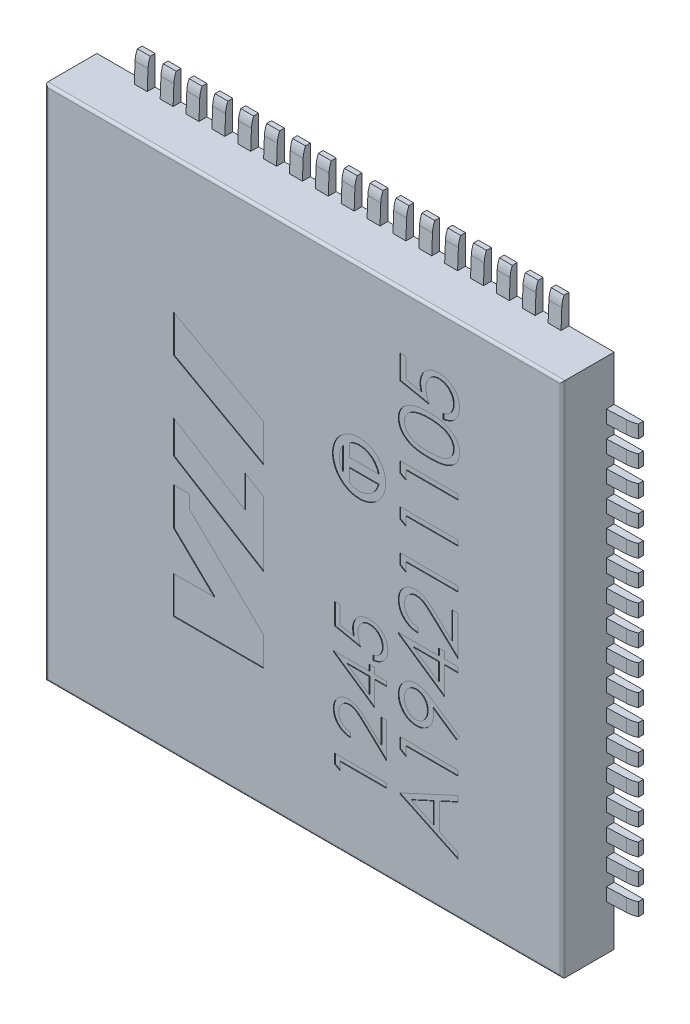
from build123d import *

# Parameters (mm, degrees)
SKETCH1_W                  = 8
SKETCH1_H                  = 8
BOSS_EXTRUDE1_DEPTH        = 0.8
FILLET1_R                  = 0.04
SKETCH3_W                  = 0.2
SKETCH3_H                  = 0.45
BOSS_EXTRUDE2_DEPTH        = 0.15
CUT_EXTRUDE2_DEPTH         = 9.586763069
LPATTERN1_COUNT            = 17
LPATTERN1_PITCH            = 0.4
SKETCH5_R                  = 2.5
BOSS_EXTRUDE3_DEPTH        = 0.1
CIRPATTERN1_COUNT          = 4
SZKIC1_R                   = 0.411647508
WYTNIJ_WYCI_GNI_CIE1_DEPTH = 0.01
WYTNIJ_WYCI_GNI_CIE2_DEPTH = 0.01


with BuildPart() as part:
    # Sketch1 → Boss-Extrude1 (new body)
    with BuildSketch(Plane.XY):
        Rectangle(SKETCH1_W, SKETCH1_H)
    extrude(amount=BOSS_EXTRUDE1_DEPTH)

    # Fillet1
    fillet1_edges = [part.edges().sort_by_distance(p)[0] for p in [
        (4, 0, 0.8),
        (0, 4, 0.8),
        (-4, 0, 0.8),
        (0, -4, 0.8),
    ]]
    fillet(fillet1_edges, radius=FILLET1_R)

    # Szkic1 → Wytnij-wyciągnięcie1 (cut)
    with BuildSketch(Plane.XY.offset(0.8)):
        with Locations((0.855307319, 1.272637091)):
            Circle(SZKIC1_R)
        with BuildLine():
            Line((1.152633787, 1.201855815), (0.704434239, 1.201855815))
            Line((0.704434239, 1.201855815), (0.704434239, 1.006835791))
            ThreePointArc((0.704434239, 1.006835791), (0.977251368, 0.992382445), (1.152633787, 1.201855815))
        make_face(mode=Mode.SUBTRACT)
        with BuildLine():
            Line((1.152633787, 1.343418368), (0.704434239, 1.343418368))
            Line((0.704434239, 1.343418368), (0.704434239, 1.538438391))
            ThreePointArc((0.704434239, 1.538438391), (0.977251368, 1.552891737), (1.152633787, 1.343418368))
        make_face(mode=Mode.SUBTRACT)
        with BuildLine():
            Line((0.601420297, 1.102477174), (0.601420297, 1.442797008))
            ThreePointArc((0.601420297, 1.442797008), (0.549671887, 1.272637091), (0.601420297, 1.102477174))
        make_face(mode=Mode.SUBTRACT)
        Polygon((-2.01662611, -2.147052964), (-2.01662611, -1.573244018), (-1.38543627, -1.573244018), (-2.012111681, -0.967285149), (-2.012111681, -0.383894567), (-1.771453197, -0.383894567), (-1.771453197, -0.58733592), (-0.623213494, -1.697617287), (-0.623213494, -2.147052964), align=None)
        Polygon((-2.012111681, 0), (-2.012111681, 0.508995767), (-0.912436965, -0.170202966), (-0.912436965, 0.3284542), (-0.623213494, 0.149819362), (-0.623213494, -0.852189973), align=None)
        Polygon((-2.012111681, 1.348953622), (-2.012111681, 1.929165418), (-0.623213494, 1.158436315), (-0.623213494, 0.578224518), align=None)
    extrude(amount=-WYTNIJ_WYCI_GNI_CIE1_DEPTH, mode=Mode.SUBTRACT)

    # Szkic2 → Wytnij-wyciągnięcie2 (cut)
    with BuildSketch(Plane.XY.offset(0.8)):
        Polygon((0.477972485, -2.880210932), (0.477972485, -2.732294265), (1.277972485, -2.732294265), (1.277972485, -2.804089137), (0.560023767, -2.804089137), (0.560023767, -2.92716606), align=None)
        with BuildLine():
            Line((0.724126331, -2.332294265), (0.724126331, -2.404089137))
            add(Edge.make_bspline(
                [(0.724126331, -2.404089137), (0.714601557, -2.403621216), (0.695895153, -2.402702232), (0.668621118, -2.398398623), (0.642551449, -2.392240709), (0.617895469, -2.38353409), (0.59443517, -2.372721227), (0.572263738, -2.359754364), (0.551465752, -2.344395769), (0.532234016, -2.326977087), (0.514591143, -2.308058541), (0.499355659, -2.287645755), (0.486483048, -2.266195463), (0.475721622, -2.243772743), (0.467643943, -2.220124614), (0.461650425, -2.195465675), (0.458044403, -2.169687587), (0.457656795, -2.152124153), (0.457459664, -2.143191701)],
                knots=[0, 0, 0, 0, 1.10065271, 2.161652631, 3.183658789, 4.190468796, 5.17591951, 6.163126047, 7.15150782, 8.156236427, 9.156009102, 10.134482811, 11.092018607, 12.041330605, 13.001268258, 13.972401359, 14.968799086, 16, 16, 16, 16], degree=3))
            add(Edge.make_bspline(
                [(0.457459664, -2.143191701), (0.457663359, -2.134418952), (0.458063613, -2.117180815), (0.461552566, -2.092032516), (0.466899077, -2.068035008), (0.474821763, -2.045460253), (0.484763001, -2.024076572), (0.497126234, -2.00414873), (0.511326474, -1.985194852), (0.528076353, -1.968145159), (0.545948516, -1.95248296), (0.565035836, -1.938983091), (0.584772713, -1.927356897), (0.60531332, -1.917841221), (0.626724548, -1.910627916), (0.648801119, -1.905283547), (0.671797813, -1.902228418), (0.687365474, -1.901762109), (0.695280177, -1.901525034)],
                knots=[0, 0, 0, 0, 1.111674182, 2.184400057, 3.212814286, 4.223731311, 5.211378316, 6.196328225, 7.191884489, 8.207283132, 9.220262353, 10.201199469, 11.166417575, 12.120932471, 13.06540007, 14.026332106, 14.996573967, 16, 16, 16, 16], degree=3))
            add(Edge.make_bspline(
                [(0.695280177, -1.901525034), (0.706422534, -1.901912072), (0.728511717, -1.902679355), (0.760972327, -1.909242552), (0.792421984, -1.919493522), (0.81773423, -1.931834682), (0.838128526, -1.944287974), (0.854928473, -1.955498974), (0.873012738, -1.968697944), (0.892454518, -1.983772116), (0.912999207, -2.00098109), (0.935065971, -2.019877779), (0.95824678, -2.040950195), (0.9740899, -2.055727025), (0.982299408, -2.063384009)],
                knots=[0, 0, 0, 0, 1.184416499, 2.348048165, 3.509039915, 4.696071444, 5.333504901, 6.05069495, 6.844171097, 7.714965912, 8.667477798, 9.695072654, 10.805644396, 12, 12, 12, 12], degree=3))
            Line((0.982299408, -2.063384009), (1.195921203, -2.263544265))
            Line((1.195921203, -2.263544265), (1.195921203, -1.891268624))
            Line((1.195921203, -1.891268624), (1.277972485, -1.891268624))
            Line((1.277972485, -1.891268624), (1.277972485, -2.434858368))
            Line((1.277972485, -2.434858368), (0.946882741, -2.124601957))
            add(Edge.make_bspline(
                [(0.946882741, -2.124601957), (0.938997414, -2.117048155), (0.923851314, -2.102538846), (0.901738638, -2.082017114), (0.881224457, -2.063585345), (0.862347531, -2.047124227), (0.844831745, -2.032990854), (0.829244384, -2.020448629), (0.814900509, -2.010399352), (0.798274083, -1.999492975), (0.777974125, -1.98892978), (0.753166425, -1.97985267), (0.727628767, -1.974317847), (0.710371159, -1.973653885), (0.701690434, -1.973319906)],
                knots=[0, 0, 0, 0, 1.329631726, 2.553950428, 3.673215718, 4.687767853, 5.603093632, 6.413772471, 7.123043292, 7.734684054, 8.834405432, 9.900288307, 10.943827018, 12, 12, 12, 12], degree=3))
            add(Edge.make_bspline(
                [(0.701690434, -1.973319906), (0.696231828, -1.973465219), (0.685473965, -1.973751602), (0.66970122, -1.976279075), (0.654486406, -1.98009862), (0.639782721, -1.985571821), (0.625738001, -1.992796219), (0.612335148, -2.001590135), (0.599377671, -2.011736435), (0.587228345, -2.023473868), (0.576101213, -2.036367929), (0.566244279, -2.049989472), (0.558006768, -2.064400925), (0.551253968, -2.079541524), (0.545956738, -2.09536906), (0.542286206, -2.111914144), (0.539981638, -2.129131062), (0.539669827, -2.14088729), (0.539510946, -2.146877598)],
                knots=[0, 0, 0, 0, 0.991446411, 1.95395049, 2.89581595, 3.838931463, 4.798493298, 5.75982156, 6.748411868, 7.785213223, 8.824556874, 9.840280684, 10.836137867, 11.835679398, 12.848801643, 13.863922112, 14.911575587, 16, 16, 16, 16], degree=3))
            add(Edge.make_bspline(
                [(0.539510946, -2.146877598), (0.539667933, -2.153135359), (0.53997623, -2.165424567), (0.542311422, -2.183429548), (0.545851574, -2.200724117), (0.551474109, -2.217050225), (0.558117413, -2.232761402), (0.566557015, -2.24752224), (0.57636402, -2.261577813), (0.587735642, -2.274696936), (0.600512482, -2.286678871), (0.614593441, -2.297354601), (0.629877148, -2.306621134), (0.646300876, -2.31471739), (0.664028143, -2.321289356), (0.682991994, -2.326312007), (0.703111222, -2.330286083), (0.717004948, -2.331613753), (0.724126331, -2.332294265)],
                knots=[0, 0, 0, 0, 1.030878251, 2.024474673, 2.987898669, 3.934362936, 4.864849709, 5.795128259, 6.730474222, 7.685293701, 8.650606017, 9.611896181, 10.591709709, 11.591680886, 12.625074257, 13.701333388, 14.821793024, 16, 16, 16, 16], degree=3))
        make_face()
        Polygon((0.457459664, -1.382775034), (0.457459664, -1.368191701), (1.011305818, -1.368191701), (1.011305818, -1.275884009), (1.0933571, -1.275884009), (1.0933571, -1.368191701), (1.277972485, -1.368191701), (1.277972485, -1.439986573), (1.0933571, -1.439986573), (1.0933571, -1.819473752), align=None)
        Polygon((1.011305818, -1.439986573), (0.663869921, -1.439986573), (1.011305818, -1.678448111), align=None, mode=Mode.SUBTRACT)
        with BuildLine():
            Line((0.477972485, -0.701525034), (0.560023767, -0.701525034))
            Line((0.560023767, -0.701525034), (0.560023767, -0.973640419))
            Line((0.560023767, -0.973640419), (0.770440434, -1.016749393))
            add(Edge.make_bspline(
                [(0.770440434, -1.016749393), (0.768102086, -1.008279479), (0.763571907, -0.99187036), (0.758542016, -0.967650963), (0.755509915, -0.94465846), (0.755095901, -0.929738375), (0.754895562, -0.922518624)],
                knots=[0, 0, 0, 0, 1.100273476, 2.13160584, 3.095893838, 4, 4, 4, 4], degree=3))
            add(Edge.make_bspline(
                [(0.754895562, -0.922518624), (0.755082533, -0.913583558), (0.755450165, -0.896014986), (0.759189859, -0.870350002), (0.764606502, -0.84572661), (0.772951866, -0.822508375), (0.783143044, -0.800327958), (0.795979054, -0.779566282), (0.810965065, -0.759931957), (0.828023895, -0.741560684), (0.84699318, -0.72497257), (0.8674733, -0.710558046), (0.889017344, -0.69797684), (0.912130262, -0.688164629), (0.936376135, -0.680156907), (0.962034843, -0.674876595), (0.988878594, -0.671349576), (1.007234137, -0.670956332), (1.01659428, -0.670755803)],
                knots=[0, 0, 0, 0, 1.052805225, 2.070078116, 3.052532748, 4.020689046, 4.973125432, 5.925915817, 6.89216474, 7.881560752, 8.877013184, 9.857446635, 10.830895175, 11.812622661, 12.812548702, 13.836681939, 14.896847428, 16, 16, 16, 16], degree=3))
            add(Edge.make_bspline(
                [(1.01659428, -0.670755803), (1.023113604, -0.670907958), (1.036064148, -0.67121021), (1.055297706, -0.672743879), (1.074121274, -0.675708083), (1.092500345, -0.679639538), (1.11045213, -0.684887837), (1.128077141, -0.691026677), (1.145182385, -0.698656848), (1.16184341, -0.707115744), (1.177869536, -0.716482379), (1.192876507, -0.727014951), (1.207206785, -0.7379589), (1.220434783, -0.749917184), (1.232611811, -0.762753846), (1.243798068, -0.776397459), (1.254194315, -0.790724275), (1.263375477, -0.805959939), (1.27182419, -0.821763887), (1.278755275, -0.838364635), (1.284951969, -0.85538422), (1.289891289, -0.873067621), (1.293761588, -0.891374778), (1.296390296, -0.91033587), (1.298304911, -0.929851451), (1.298424764, -0.943080026), (1.298485305, -0.949762214)],
                knots=[0, 0, 0, 0, 1.056393913, 2.098511576, 3.122979385, 4.141471433, 5.141222888, 6.151259816, 7.162667642, 8.172852865, 9.177685681, 10.166741883, 11.141342384, 12.097242845, 13.052202613, 14.005160326, 14.953864445, 15.917140761, 16.884916217, 17.854238259, 18.828761908, 19.81781811, 20.826036654, 21.857789401, 22.917898972, 24, 24, 24, 24], degree=3))
            add(Edge.make_bspline(
                [(1.298485305, -0.949762214), (1.298326975, -0.957733252), (1.298015478, -0.973415327), (1.294771592, -0.996394354), (1.290094877, -1.018489969), (1.283166069, -1.039607473), (1.274093289, -1.059658794), (1.263313453, -1.078931062), (1.250480224, -1.097185406), (1.235710983, -1.114297027), (1.219482698, -1.1300264), (1.202040471, -1.144289911), (1.183362088, -1.156830171), (1.163508286, -1.167692669), (1.14251428, -1.176946527), (1.120315383, -1.184219306), (1.097023776, -1.19008843), (1.080988712, -1.192571527), (1.07284428, -1.193832727)],
                knots=[0, 0, 0, 0, 1.046872515, 2.059598001, 3.044168548, 4.012104806, 4.973680974, 5.932408326, 6.910122221, 7.900780896, 8.89867654, 9.876692837, 10.858029398, 11.85084981, 12.847361615, 13.868568023, 14.917415949, 16, 16, 16, 16], degree=3))
            Line((1.07284428, -1.193832727), (1.07284428, -1.122037855))
            add(Edge.make_bspline(
                [(1.07284428, -1.122037855), (1.080473977, -1.120272432), (1.09513868, -1.116879193), (1.115729559, -1.109411743), (1.134085029, -1.100370151), (1.150317317, -1.089368108), (1.164723552, -1.076615332), (1.177425497, -1.061790889), (1.188898822, -1.045265385), (1.198478823, -1.02689227), (1.206548682, -1.007470998), (1.212307598, -0.987260005), (1.215793594, -0.966550164), (1.216219743, -0.952606708), (1.216434023, -0.945595547)],
                knots=[0, 0, 0, 0, 1.13623081, 2.183898708, 3.172478118, 4.09966615, 5.022692284, 5.957376522, 6.927682873, 7.937366477, 8.960015386, 9.976409503, 10.982481913, 12, 12, 12, 12], degree=3))
            add(Edge.make_bspline(
                [(1.216434023, -0.945595547), (1.216244847, -0.938748483), (1.215872358, -0.925266559), (1.21305167, -0.905415625), (1.208593378, -0.88630631), (1.202347566, -0.867904692), (1.194084723, -0.850301195), (1.183934296, -0.833520706), (1.17214953, -0.817324174), (1.158679973, -0.802137868), (1.143828083, -0.788232441), (1.127947973, -0.775945136), (1.111006865, -0.765710463), (1.093298746, -0.75708551), (1.074629354, -0.750536189), (1.05508623, -0.745863963), (1.034621091, -0.743120407), (1.020662392, -0.742742995), (1.013549408, -0.742550675)],
                knots=[0, 0, 0, 0, 1.027268864, 2.022700798, 3.002744649, 3.968653148, 4.933396556, 5.915045722, 6.907600446, 7.935526002, 8.956456544, 9.95700807, 10.942805781, 11.92166854, 12.907987664, 13.905483474, 14.932689774, 16, 16, 16, 16], degree=3))
            add(Edge.make_bspline(
                [(1.013549408, -0.742550675), (1.007131335, -0.742696612), (0.994621846, -0.742981057), (0.976255983, -0.745443481), (0.958850547, -0.749556921), (0.942329804, -0.755413624), (0.926746576, -0.762722977), (0.912135202, -0.771900091), (0.898358298, -0.782554197), (0.885770402, -0.794992624), (0.874134065, -0.808523058), (0.864250363, -0.82349303), (0.85584508, -0.839502896), (0.848958436, -0.856582326), (0.843472696, -0.874752357), (0.839681427, -0.894022776), (0.837412789, -0.914397974), (0.837105036, -0.928335264), (0.836946844, -0.935499393)],
                knots=[0, 0, 0, 0, 1.045723156, 2.038222538, 3.013889863, 3.95567481, 4.890389958, 5.81331128, 6.76251276, 7.723027653, 8.692928204, 9.666105983, 10.639751036, 11.635719707, 12.66315958, 13.728667616, 14.832476222, 16, 16, 16, 16], degree=3))
            add(Edge.make_bspline(
                [(0.836946844, -0.935499393), (0.83707955, -0.941700291), (0.837353556, -0.954503572), (0.839371041, -0.974143076), (0.842625737, -0.994781184), (0.847102593, -1.016338783), (0.852961125, -1.038880613), (0.859981582, -1.062359105), (0.868375182, -1.086823623), (0.874713974, -1.103307674), (0.877972485, -1.111781444)],
                knots=[0, 0, 0, 0, 0.817624296, 1.688186739, 2.600797293, 3.572016777, 4.590301741, 5.671205678, 6.80286297, 8, 8, 8, 8], degree=3))
            Line((0.877972485, -1.111781444), (0.477972485, -1.029730162))
            Line((0.477972485, -1.029730162), (0.477972485, -0.701525034))
        make_face()
        Polygon((1.48522985, -2.761153846), (2.38522985, -2.345769231), (2.38522985, -2.433569712), (2.096768311, -2.566622596), (2.096768311, -2.974615385), (2.38522985, -3.111454327), (2.38522985, -3.199615385), (1.48522985, -2.772692308), align=None)
        Polygon((1.660650523, -2.767824519), (2.004460619, -2.930805288), (2.004460619, -2.609170673), align=None, mode=Mode.SUBTRACT)
        Polygon((1.48522985, -2.172944712), (1.48522985, -2.006538462), (2.38522985, -2.006538462), (2.38522985, -2.087307692), (1.577537542, -2.087307692), (1.577537542, -2.225769231), align=None)
        with BuildLine():
            Line((2.408306773, -1.551923077), (2.363414946, -1.616466346))
            Line((2.363414946, -1.616466346), (1.997609658, -1.366225962))
            add(Edge.make_bspline(
                [(1.997609658, -1.366225962), (1.999653267, -1.382189943), (2.003676179, -1.413615567), (2.00420194, -1.445292243), (2.004460619, -1.460877404)],
                knots=[0, 0, 0, 0, 1.015985029, 2, 2, 2, 2], degree=3))
            add(Edge.make_bspline(
                [(2.004460619, -1.460877404), (2.004218628, -1.470325359), (2.003743621, -1.488870869), (1.999978584, -1.516136151), (1.99417998, -1.542335294), (1.985527444, -1.567398847), (1.974774184, -1.591420991), (1.961439548, -1.614349371), (1.94575212, -1.636152794), (1.927795431, -1.656598342), (1.908076862, -1.675189876), (1.887213156, -1.691766374), (1.864979089, -1.705467703), (1.841843584, -1.717052596), (1.817312836, -1.725592023), (1.791803088, -1.731960741), (1.76515599, -1.735838748), (1.747021521, -1.73630283), (1.737813985, -1.736538462)],
                knots=[0, 0, 0, 0, 1.060698949, 2.082059282, 3.085738422, 4.069684654, 5.054463875, 6.037298355, 7.043153692, 8.066652628, 9.088369706, 10.083456696, 11.053578809, 12.016466116, 12.983507685, 13.964045196, 14.966270913, 16, 16, 16, 16], degree=3))
            add(Edge.make_bspline(
                [(1.737813985, -1.736538462), (1.725222531, -1.736091568), (1.700508061, -1.735214406), (1.664389612, -1.728181829), (1.630219171, -1.716530148), (1.59803495, -1.700538821), (1.568576219, -1.680011053), (1.541942786, -1.655632807), (1.518609754, -1.627207051), (1.498575599, -1.595475936), (1.482353165, -1.561230454), (1.470827816, -1.525216027), (1.463465155, -1.488039341), (1.462592222, -1.462774441), (1.462152927, -1.450060096)],
                knots=[0, 0, 0, 0, 1.023011052, 2.007963168, 2.978169221, 3.950402619, 4.919353283, 5.887490769, 6.876420893, 7.899700203, 8.931203047, 9.947778163, 10.96723692, 12, 12, 12, 12], degree=3))
            add(Edge.make_bspline(
                [(1.462152927, -1.450060096), (1.462623543, -1.43759165), (1.463553435, -1.412955174), (1.470363562, -1.376726513), (1.481841703, -1.342027619), (1.497702922, -1.30904949), (1.517587395, -1.27851964), (1.541271977, -1.251051506), (1.568776447, -1.227373992), (1.599345262, -1.207187064), (1.632392084, -1.19128443), (1.666821382, -1.179631836), (1.702426062, -1.172509022), (1.726543812, -1.171608378), (1.738715427, -1.171153846)],
                knots=[0, 0, 0, 0, 1.026358223, 2.027987109, 3.023239252, 4.028077889, 5.032770297, 6.015020143, 7.004250571, 8.011656937, 9.02310243, 10.015224881, 10.998334443, 12, 12, 12, 12], degree=3))
            add(Edge.make_bspline(
                [(1.738715427, -1.171153846), (1.748163477, -1.171458215), (1.767326483, -1.172075552), (1.796390435, -1.176349328), (1.826000685, -1.183721308), (1.851087317, -1.191958476), (1.871870241, -1.200032287), (1.888335432, -1.207412942), (1.905545369, -1.215986591), (1.923570526, -1.225561791), (1.94243442, -1.236120401), (1.962006216, -1.247949452), (1.982314449, -1.260889394), (1.996006867, -1.270102155), (2.003018311, -1.274819712)],
                knots=[0, 0, 0, 0, 1.179894106, 2.393120058, 3.660107319, 4.986885617, 5.687958251, 6.443931318, 7.239444731, 8.088894906, 8.992865148, 9.938946712, 10.944601238, 12, 12, 12, 12], degree=3))
            Line((2.003018311, -1.274819712), (2.408306773, -1.551923077))
        make_face()
        with BuildLine():
            add(Edge.make_bspline(
                [(1.912152927, -1.445913462), (1.911956995, -1.438756315), (1.911575581, -1.424823785), (1.909264537, -1.404410096), (1.905136713, -1.385152455), (1.899307648, -1.366926917), (1.891923387, -1.349755547), (1.882924457, -1.333632936), (1.872113709, -1.31872377), (1.859962212, -1.304974969), (1.846644654, -1.292497514), (1.832376128, -1.281739072), (1.817599907, -1.272424208), (1.8020135, -1.264993029), (1.785871883, -1.259004259), (1.768941617, -1.254825505), (1.751339596, -1.252517522), (1.739382936, -1.252123375), (1.733306773, -1.251923077)],
                knots=[0, 0, 0, 0, 1.163726718, 2.265380301, 3.334713825, 4.36057981, 5.371541381, 6.368955992, 7.355979581, 8.359691305, 9.348261197, 10.317521986, 11.261029684, 12.183096459, 13.119698615, 14.055740009, 15.011961376, 16, 16, 16, 16], degree=3))
            add(Edge.make_bspline(
                [(1.733306773, -1.251923077), (1.727227919, -1.252095111), (1.715248791, -1.252434124), (1.697622911, -1.255158971), (1.680725907, -1.259939387), (1.664442749, -1.266418462), (1.648862454, -1.274791686), (1.633935915, -1.284936998), (1.619889068, -1.297187677), (1.606490411, -1.310877264), (1.594335562, -1.325934173), (1.583596447, -1.341887062), (1.574533221, -1.358650707), (1.56737637, -1.376299891), (1.561513226, -1.394594944), (1.557362654, -1.413725262), (1.555050282, -1.433717286), (1.554659677, -1.447289924), (1.554460619, -1.454206731)],
                knots=[0, 0, 0, 0, 0.971910406, 1.91526867, 2.84337505, 3.775008003, 4.712374136, 5.666733183, 6.654995996, 7.688089235, 8.726800303, 9.745078658, 10.75990398, 11.768337501, 12.786615857, 13.829099629, 14.893678693, 16, 16, 16, 16], degree=3))
            add(Edge.make_bspline(
                [(1.554460619, -1.454206731), (1.554660004, -1.461063382), (1.555051195, -1.474516075), (1.557358211, -1.494330379), (1.561541422, -1.513331315), (1.567373713, -1.531573262), (1.574533769, -1.549221935), (1.583596925, -1.565984789), (1.594333069, -1.581941394), (1.606500089, -1.596983979), (1.619826589, -1.610698241), (1.633998681, -1.62274162), (1.648854552, -1.632909874), (1.664444837, -1.641271402), (1.680725352, -1.647753571), (1.697623061, -1.65253316), (1.715248752, -1.655258229), (1.727227906, -1.655597212), (1.733306773, -1.655769231)],
                knots=[0, 0, 0, 0, 1.099107991, 2.156440826, 3.191784126, 4.212280276, 5.222910149, 6.239945746, 7.260441896, 8.30141526, 9.33675856, 10.320924759, 11.277362386, 12.216770088, 13.150432123, 14.080559904, 15.025972789, 16, 16, 16, 16], degree=3))
            add(Edge.make_bspline(
                [(1.733306773, -1.655769231), (1.73938765, -1.655613252), (1.751380252, -1.655305633), (1.769002598, -1.652343782), (1.785889101, -1.64737742), (1.802183911, -1.640791997), (1.817676215, -1.631954169), (1.832446348, -1.621213653), (1.846796265, -1.608820931), (1.859920572, -1.594369865), (1.872171869, -1.57885192), (1.882856484, -1.562183994), (1.891815861, -1.544701038), (1.899329415, -1.526515304), (1.905077914, -1.507490715), (1.90925687, -1.487653763), (1.911553425, -1.467000873), (1.911951176, -1.453010037), (1.912152927, -1.445913462)],
                knots=[0, 0, 0, 0, 0.952872936, 1.879239831, 2.791748947, 3.708674669, 4.628500839, 5.580394867, 6.568761142, 7.595635223, 8.636123962, 9.665976811, 10.694276597, 11.712685318, 12.747011694, 13.805940053, 14.887106426, 16, 16, 16, 16], degree=3))
        make_face(mode=Mode.SUBTRACT)
        Polygon((1.462152927, -0.640637019), (1.462152927, -0.624230769), (2.08522985, -0.624230769), (2.08522985, -0.520384615), (2.177537542, -0.520384615), (2.177537542, -0.624230769), (2.38522985, -0.624230769), (2.38522985, -0.705), (2.177537542, -0.705), (2.177537542, -1.131923077), align=None)
        Polygon((2.08522985, -0.705), (1.694364465, -0.705), (2.08522985, -0.973269231), align=None, mode=Mode.SUBTRACT)
        with BuildLine():
            Line((1.762152927, -0.400384615), (1.762152927, -0.481153846))
            add(Edge.make_bspline(
                [(1.762152927, -0.481153846), (1.751437556, -0.480627435), (1.730392852, -0.479593579), (1.699709562, -0.474752019), (1.670381185, -0.467824364), (1.642643207, -0.458029419), (1.616250371, -0.445864948), (1.59130751, -0.431277226), (1.567909775, -0.413998808), (1.546274073, -0.39440279), (1.52642584, -0.373119426), (1.509285921, -0.350155042), (1.494804234, -0.326023463), (1.482697629, -0.300797903), (1.47361024, -0.274193758), (1.466867533, -0.246452452), (1.462810758, -0.217452103), (1.462374699, -0.19769324), (1.462152927, -0.187644231)],
                knots=[0, 0, 0, 0, 1.10065271, 2.161652631, 3.183658789, 4.190468796, 5.17591951, 6.163126047, 7.15150782, 8.156236427, 9.156009102, 10.134482811, 11.092018607, 12.041330605, 13.001268258, 13.972401359, 14.968799086, 16, 16, 16, 16], degree=3))
            add(Edge.make_bspline(
                [(1.462152927, -0.187644231), (1.462382084, -0.177774889), (1.462832369, -0.158381984), (1.466757442, -0.130090148), (1.472772266, -0.103092951), (1.481685288, -0.077696352), (1.492869181, -0.053639711), (1.506777818, -0.031220889), (1.522753087, -0.009897775), (1.541596701, 0.009283129), (1.561702885, 0.026903103), (1.58317612, 0.042090456), (1.605380107, 0.055169923), (1.62848829, 0.065875059), (1.652575921, 0.073990028), (1.677412064, 0.080002442), (1.703283344, 0.083439463), (1.720796963, 0.08396406), (1.729701004, 0.084230769)],
                knots=[0, 0, 0, 0, 1.111674182, 2.184400057, 3.212814286, 4.223731311, 5.211378316, 6.196328225, 7.191884489, 8.207283132, 9.220262353, 10.201199469, 11.166417575, 12.120932471, 13.06540007, 14.026332106, 14.996573967, 16, 16, 16, 16], degree=3))
            add(Edge.make_bspline(
                [(1.729701004, 0.084230769), (1.742236156, 0.083795352), (1.767086486, 0.082932158), (1.803604672, 0.075548562), (1.838985536, 0.06401622), (1.867461813, 0.050132416), (1.890405396, 0.036122462), (1.909305336, 0.023510087), (1.929650135, 0.008661246), (1.951522138, -0.008297198), (1.974634912, -0.027657294), (1.999460022, -0.048916068), (2.025538432, -0.072622537), (2.043361942, -0.089246471), (2.052597638, -0.097860577)],
                knots=[0, 0, 0, 0, 1.184416499, 2.348048165, 3.509039915, 4.696071444, 5.333504901, 6.05069495, 6.844171097, 7.714965912, 8.667477798, 9.695072654, 10.805644396, 12, 12, 12, 12], degree=3))
            Line((2.052597638, -0.097860577), (2.292922158, -0.323040865))
            Line((2.292922158, -0.323040865), (2.292922158, 0.095769231))
            Line((2.292922158, 0.095769231), (2.38522985, 0.095769231))
            Line((2.38522985, 0.095769231), (2.38522985, -0.515769231))
            Line((2.38522985, -0.515769231), (2.012753888, -0.166730769))
            add(Edge.make_bspline(
                [(2.012753888, -0.166730769), (2.003882895, -0.158232741), (1.986843533, -0.141909769), (1.961966772, -0.11882282), (1.938888319, -0.09808708), (1.917651777, -0.079568322), (1.897946517, -0.063668278), (1.880410736, -0.049558275), (1.864273878, -0.038252838), (1.845569148, -0.025983165), (1.822731695, -0.014099569), (1.794823032, -0.003887821), (1.766093167, 0.002338855), (1.746678358, 0.003085812), (1.736912542, 0.003461538)],
                knots=[0, 0, 0, 0, 1.329631726, 2.553950428, 3.673215718, 4.687767853, 5.603093632, 6.413772471, 7.123043292, 7.734684054, 8.834405432, 9.900288307, 10.943827018, 12, 12, 12, 12], degree=3))
            add(Edge.make_bspline(
                [(1.736912542, 0.003461538), (1.730771611, 0.003298062), (1.718669015, 0.002975881), (1.700924677, 0.000132473), (1.683808011, -0.004164514), (1.667266366, -0.010321866), (1.651466056, -0.018449314), (1.636387846, -0.028342469), (1.621810684, -0.039757056), (1.608142693, -0.052961669), (1.595624669, -0.067467488), (1.584535618, -0.082791723), (1.575268418, -0.099004607), (1.567671519, -0.116037782), (1.561712135, -0.13384376), (1.557582786, -0.15245698), (1.554990147, -0.171826013), (1.55463936, -0.185051769), (1.554460619, -0.191790865)],
                knots=[0, 0, 0, 0, 0.991446411, 1.95395049, 2.89581595, 3.838931463, 4.798493298, 5.75982156, 6.748411868, 7.785213223, 8.824556874, 9.840280684, 10.836137867, 11.835679398, 12.848801643, 13.863922112, 14.911575587, 16, 16, 16, 16], degree=3))
            add(Edge.make_bspline(
                [(1.554460619, -0.191790865), (1.55463723, -0.198830846), (1.554984063, -0.212656206), (1.557611154, -0.232911809), (1.561593826, -0.252368199), (1.567919177, -0.27073507), (1.575392894, -0.288410144), (1.584887446, -0.305016087), (1.595920327, -0.320828607), (1.608713402, -0.33558762), (1.623087346, -0.349067297), (1.638928425, -0.361077494), (1.656122596, -0.371502343), (1.67459929, -0.38061063), (1.694542466, -0.388004093), (1.715876798, -0.393654575), (1.738510929, -0.39812541), (1.754141371, -0.399619039), (1.762152927, -0.400384615)],
                knots=[0, 0, 0, 0, 1.030878251, 2.024474673, 2.987898669, 3.934362936, 4.864849709, 5.795128259, 6.730474222, 7.685293701, 8.650606017, 9.611896181, 10.591709709, 11.591680886, 12.625074257, 13.701333388, 14.821793024, 16, 16, 16, 16], degree=3))
        make_face()
        Polygon((1.48522985, 0.291670673), (1.48522985, 0.458076923), (2.38522985, 0.458076923), (2.38522985, 0.377307692), (1.577537542, 0.377307692), (1.577537542, 0.238846154), align=None)
        Polygon((1.48522985, 0.907824519), (1.48522985, 1.074230769), (2.38522985, 1.074230769), (2.38522985, 0.993461538), (1.577537542, 0.993461538), (1.577537542, 0.855), align=None)
        Polygon((1.48522985, 1.523978365), (1.48522985, 1.690384615), (2.38522985, 1.690384615), (2.38522985, 1.609615385), (1.577537542, 1.609615385), (1.577537542, 1.471153846), align=None)
        with BuildLine():
            add(Edge.make_bspline(
                [(1.935590427, 1.948846154), (1.921165384, 1.948930501), (1.893144531, 1.949094348), (1.852314195, 1.950917084), (1.81401012, 1.95394503), (1.778230475, 1.95809464), (1.744966021, 1.963144406), (1.714305657, 1.969885533), (1.686107465, 1.977551675), (1.660279533, 1.986436612), (1.636473757, 1.996461968), (1.61425042, 2.007373902), (1.593641478, 2.019603902), (1.574323966, 2.032458493), (1.556592916, 2.046438101), (1.540244034, 2.061242977), (1.525415191, 2.077169222), (1.512096234, 2.094062364), (1.500417453, 2.111807911), (1.490067029, 2.129920944), (1.48154144, 2.148725102), (1.474567274, 2.16797284), (1.468874101, 2.187704723), (1.464963475, 2.207915716), (1.46250729, 2.228652667), (1.462272169, 2.24264924), (1.462152927, 2.249747596)],
                knots=[0, 0, 0, 0, 1.646148282, 3.197666765, 4.66315463, 6.030252048, 7.307778049, 8.501004361, 9.610818041, 10.641065266, 11.615491391, 12.557119604, 13.464013759, 14.348536654, 15.203310953, 16.038349431, 16.863300206, 17.683791446, 18.490318933, 19.285717724, 20.06220424, 20.843281102, 21.620494212, 22.403315558, 23.190242141, 24, 24, 24, 24], degree=3))
            add(Edge.make_bspline(
                [(1.462152927, 2.249747596), (1.462252248, 2.256908762), (1.462449863, 2.271156961), (1.465231408, 2.292146285), (1.468821628, 2.312770011), (1.47457975, 2.332715235), (1.481470091, 2.352359085), (1.490561785, 2.371213057), (1.500449708, 2.389942795), (1.512512143, 2.407697433), (1.525843119, 2.425007448), (1.540977185, 2.441233779), (1.557495503, 2.456791215), (1.575766481, 2.471092158), (1.595509971, 2.484749526), (1.616891479, 2.497244873), (1.639863622, 2.508838078), (1.664319903, 2.519747063), (1.690913589, 2.529286682), (1.719478807, 2.537768166), (1.750274229, 2.544720177), (1.783128305, 2.550469368), (1.818203794, 2.554931835), (1.855429628, 2.558179543), (1.894829097, 2.559895674), (1.921766838, 2.560218798), (1.935590427, 2.560384615)],
                knots=[0, 0, 0, 0, 0.810910589, 1.61342667, 2.396193133, 3.181089899, 3.963115317, 4.752255436, 5.550715454, 6.36105385, 7.181178335, 8.024612154, 8.872680183, 9.750181803, 10.651284446, 11.591556747, 12.554036451, 13.566402641, 14.62422919, 15.753422176, 16.94128843, 18.199818041, 19.531985927, 20.947085226, 22.433341622, 24, 24, 24, 24], degree=3))
            add(Edge.make_bspline(
                [(1.935590427, 2.560384615), (1.949353597, 2.56021515), (1.976230601, 2.559884215), (2.01545464, 2.558216349), (2.052479819, 2.554852509), (2.087345613, 2.550706152), (2.120068187, 2.544892703), (2.150626219, 2.537887977), (2.179127899, 2.529907134), (2.205369015, 2.520221107), (2.229782857, 2.509566038), (2.252586087, 2.497985273), (2.273961949, 2.48556044), (2.293757515, 2.4721079), (2.311955156, 2.457571721), (2.32853013, 2.442025189), (2.343760454, 2.425657183), (2.357238298, 2.408246255), (2.36939257, 2.390326243), (2.379639321, 2.371594602), (2.388517529, 2.352530724), (2.395776283, 2.332944276), (2.401405532, 2.312865496), (2.405275334, 2.292227635), (2.407995507, 2.271153999), (2.408202659, 2.256907771), (2.408306773, 2.249747596)],
                knots=[0, 0, 0, 0, 1.561645053, 3.049612875, 4.452756685, 5.778837748, 7.032101753, 8.221335837, 9.334924186, 10.387562255, 11.392109817, 12.355697819, 13.287721948, 14.19548756, 15.068665045, 15.927346723, 16.771751757, 17.602390507, 18.423119567, 19.225778204, 20.022010933, 20.807278863, 21.593079439, 22.384715467, 23.188155646, 24, 24, 24, 24], degree=3))
            add(Edge.make_bspline(
                [(2.408306773, 2.249747596), (2.408186853, 2.242649395), (2.407950394, 2.228653129), (2.405504006, 2.207913934), (2.401570877, 2.187784163), (2.39606375, 2.168164483), (2.38932279, 2.148954239), (2.380540422, 2.130415182), (2.370425918, 2.11234125), (2.358907208, 2.094780397), (2.345709773, 2.078063622), (2.331114882, 2.062092981), (2.314748272, 2.047284454), (2.296867618, 2.033426061), (2.277521364, 2.020435575), (2.256696529, 2.008311257), (2.234357552, 1.997170492), (2.210363637, 1.986973855), (2.18435239, 1.977933398), (2.156082319, 1.969978679), (2.125266283, 1.963625489), (2.092060742, 1.958240179), (2.056398225, 1.953924859), (2.018265829, 1.950918342), (1.977735965, 1.949095731), (1.949895301, 1.948930864), (1.935590427, 1.948846154)],
                knots=[0, 0, 0, 0, 0.810927267, 1.598990287, 2.382942141, 3.152806972, 3.926217614, 4.706701772, 5.493896336, 6.292070767, 7.104102563, 7.925577746, 8.761822141, 9.623241997, 10.509042271, 11.423174113, 12.375371989, 13.360203808, 14.400680605, 15.520553799, 16.714061498, 17.994519714, 19.364400916, 20.818312473, 22.365209998, 24, 24, 24, 24], degree=3))
        make_face()
        with BuildLine():
            add(Edge.make_bspline(
                [(1.93522985, 2.029615385), (1.947250896, 2.029646773), (1.970581386, 2.029707692), (2.004424683, 2.031253097), (2.036043363, 2.033404143), (2.065425085, 2.036110282), (2.09246716, 2.040163111), (2.117282013, 2.044761293), (2.139823711, 2.050276531), (2.160289243, 2.056834225), (2.178968408, 2.064304077), (2.196359072, 2.072445522), (2.212667347, 2.081269252), (2.227853667, 2.090956133), (2.241732396, 2.101697681), (2.254655328, 2.112995918), (2.266173014, 2.125359823), (2.279988982, 2.142460025), (2.294265099, 2.16503662), (2.306697021, 2.193481772), (2.314509635, 2.222710829), (2.315503174, 2.242549718), (2.315999081, 2.252451923)],
                knots=[0, 0, 0, 0, 1.459098681, 2.831824031, 4.11146945, 5.306290378, 6.412266529, 7.42953815, 8.369053297, 9.227277979, 10.03601793, 10.809473603, 11.557037441, 12.285528272, 12.993193355, 13.685654407, 14.36688038, 15.041354379, 16.352855396, 17.594313975, 18.799247529, 20, 20, 20, 20], degree=3))
            add(Edge.make_bspline(
                [(2.315999081, 2.252451923), (2.315564855, 2.262411448), (2.314697945, 2.282295169), (2.307131894, 2.311497376), (2.294831897, 2.339612473), (2.280779442, 2.361800609), (2.267311149, 2.378634106), (2.255841374, 2.390699479), (2.242994867, 2.401772298), (2.229135246, 2.412274623), (2.213996553, 2.421906935), (2.197651906, 2.430666034), (2.180055827, 2.438658893), (2.167772181, 2.443212648), (2.161491869, 2.445540865)],
                knots=[0, 0, 0, 0, 1.353621445, 2.702441307, 4.075953605, 5.516772412, 6.261413105, 7.007624062, 7.778524365, 8.566925914, 9.372323995, 10.217594641, 11.088702136, 12, 12, 12, 12], degree=3))
            add(Edge.make_bspline(
                [(2.161491869, 2.445540865), (2.153461365, 2.448254177), (2.137155997, 2.453763364), (2.111862486, 2.460863534), (2.085324633, 2.466455208), (2.057701031, 2.471485788), (2.028787965, 2.474919431), (1.998674895, 2.477683154), (1.967339116, 2.479311045), (1.946048976, 2.479512838), (1.93522985, 2.479615385)],
                knots=[0, 0, 0, 0, 0.884706709, 1.796334032, 2.740027952, 3.714592787, 4.726048262, 5.777819803, 6.87074269, 8, 8, 8, 8], degree=3))
            add(Edge.make_bspline(
                [(1.93522985, 2.479615385), (1.924412474, 2.479473907), (1.903251375, 2.479197148), (1.872260985, 2.478139265), (1.842826418, 2.475407489), (1.814820868, 2.47237343), (1.788399361, 2.467899859), (1.763340713, 2.463076421), (1.739955357, 2.456596116), (1.717877204, 2.449673864), (1.697356948, 2.441751276), (1.67829942, 2.433029793), (1.66061086, 2.423716656), (1.644345921, 2.413596481), (1.629410258, 2.402810234), (1.61614754, 2.390971178), (1.60391261, 2.378831183), (1.590196349, 2.36156555), (1.576100628, 2.339145601), (1.563481756, 2.311055172), (1.556013568, 2.281982788), (1.554977895, 2.262288447), (1.554460619, 2.252451923)],
                knots=[0, 0, 0, 0, 1.313483664, 2.569454835, 3.763100662, 4.901599063, 5.988328865, 7.015709358, 7.99797933, 8.932480776, 9.824041341, 10.666387587, 11.475829342, 12.24921787, 12.990555181, 13.709176526, 14.405678811, 15.080244297, 16.38186033, 17.610124501, 18.806354173, 20, 20, 20, 20], degree=3))
            add(Edge.make_bspline(
                [(1.554460619, 2.252451923), (1.554979182, 2.242496259), (1.556017254, 2.222566793), (1.563447218, 2.193183944), (1.576063707, 2.164903747), (1.590169192, 2.142409865), (1.60386002, 2.125353981), (1.615512491, 2.113250726), (1.628126765, 2.101795798), (1.642128614, 2.0913324), (1.657261425, 2.08170296), (1.673358806, 2.072538224), (1.690781964, 2.064505651), (1.709446482, 2.057011818), (1.729913139, 2.050443186), (1.752536401, 2.044990965), (1.777410513, 2.040027363), (1.804650174, 2.03645276), (1.834038166, 2.033305085), (1.865737706, 2.031276711), (1.899697218, 2.029700612), (1.923148416, 2.029644363), (1.93522985, 2.029615385)],
                knots=[0, 0, 0, 0, 1.207546505, 2.417292871, 3.651582144, 4.952510111, 5.626719005, 6.30238548, 6.989136872, 7.692112372, 8.420316868, 9.164734959, 9.937886623, 10.746308695, 11.604196049, 12.543341915, 13.568754172, 14.680483261, 15.875568977, 17.154711427, 18.534182925, 20, 20, 20, 20], degree=3))
        make_face(mode=Mode.SUBTRACT)
        with BuildLine():
            Line((1.48522985, 3.130384615), (1.577537542, 3.130384615))
            Line((1.577537542, 3.130384615), (1.577537542, 2.824254808))
            Line((1.577537542, 2.824254808), (1.814256292, 2.775757212))
            add(Edge.make_bspline(
                [(1.814256292, 2.775757212), (1.811625651, 2.785285865), (1.806529199, 2.803746124), (1.800870573, 2.830992945), (1.797459459, 2.856859512), (1.796993693, 2.873644607), (1.796768311, 2.881766827)],
                knots=[0, 0, 0, 0, 1.100273476, 2.13160584, 3.095893838, 4, 4, 4, 4], degree=3))
            add(Edge.make_bspline(
                [(1.796768311, 2.881766827), (1.796978654, 2.891818776), (1.79739224, 2.91158342), (1.801599396, 2.940456527), (1.80769312, 2.968157842), (1.817081654, 2.994278357), (1.828546729, 3.019231326), (1.842987241, 3.042588211), (1.859846503, 3.064676827), (1.879037687, 3.08534451), (1.900378132, 3.104006138), (1.923418267, 3.120222478), (1.947655317, 3.134376334), (1.973657349, 3.145415072), (2.000933956, 3.154423759), (2.029800003, 3.160364109), (2.059999223, 3.164332006), (2.080649209, 3.164774405), (2.091179369, 3.165)],
                knots=[0, 0, 0, 0, 1.052805225, 2.070078116, 3.052532748, 4.020689046, 4.973125432, 5.925915817, 6.89216474, 7.881560752, 8.877013184, 9.857446635, 10.830895175, 11.812622661, 12.812548702, 13.836681939, 14.896847428, 16, 16, 16, 16], degree=3))
            add(Edge.make_bspline(
                [(2.091179369, 3.165), (2.098513609, 3.164828827), (2.113082971, 3.164488793), (2.134720724, 3.162763415), (2.155897238, 3.159428685), (2.176573692, 3.155005798), (2.19676945, 3.149101462), (2.216597588, 3.142195268), (2.235840988, 3.133611325), (2.254584641, 3.124095066), (2.272614032, 3.113557603), (2.289496874, 3.101708459), (2.305618438, 3.089396517), (2.320499936, 3.075943446), (2.334199092, 3.061502202), (2.346783631, 3.046153137), (2.358479409, 3.030035469), (2.368808216, 3.012895347), (2.378313019, 2.995115907), (2.386110488, 2.976440065), (2.39308177, 2.957293031), (2.398638505, 2.937399205), (2.402992591, 2.916803653), (2.405949888, 2.895472425), (2.408103829, 2.873517396), (2.408238664, 2.85863525), (2.408306773, 2.851117788)],
                knots=[0, 0, 0, 0, 1.056393913, 2.098511576, 3.122979385, 4.141471433, 5.141222888, 6.151259816, 7.162667642, 8.172852865, 9.177685681, 10.166741883, 11.141342384, 12.097242845, 13.052202613, 14.005160326, 14.953864445, 15.917140761, 16.884916217, 17.854238259, 18.828761908, 19.81781811, 20.826036654, 21.857789401, 22.917898972, 24, 24, 24, 24], degree=3))
            add(Edge.make_bspline(
                [(2.408306773, 2.851117788), (2.408128651, 2.842150371), (2.407778218, 2.824508036), (2.404128846, 2.79865663), (2.398867541, 2.773799064), (2.391072632, 2.750041872), (2.380865754, 2.727484136), (2.368738439, 2.705802834), (2.354301057, 2.685266697), (2.33768566, 2.666016123), (2.31942884, 2.648320579), (2.299806334, 2.632274129), (2.278793153, 2.618166337), (2.256457626, 2.605946026), (2.232839369, 2.595535436), (2.20786561, 2.58735356), (2.181662553, 2.580750795), (2.163623106, 2.577957311), (2.154460619, 2.576538462)],
                knots=[0, 0, 0, 0, 1.046872515, 2.059598001, 3.044168548, 4.012104806, 4.973680974, 5.932408326, 6.910122221, 7.900780896, 8.89867654, 9.876692837, 10.858029398, 11.85084981, 12.847361615, 13.868568023, 14.917415949, 16, 16, 16, 16], degree=3))
            Line((2.154460619, 2.576538462), (2.154460619, 2.657307692))
            add(Edge.make_bspline(
                [(2.154460619, 2.657307692), (2.163044029, 2.659293792), (2.17954182, 2.663111187), (2.202706559, 2.671512068), (2.223356462, 2.681683859), (2.241617786, 2.694061157), (2.257824801, 2.70840803), (2.272114489, 2.725085529), (2.28502198, 2.743676721), (2.295799481, 2.764346475), (2.304878072, 2.786195406), (2.311356853, 2.808932774), (2.315278598, 2.832231345), (2.315758016, 2.847917732), (2.315999081, 2.855805288)],
                knots=[0, 0, 0, 0, 1.13623081, 2.183898708, 3.172478118, 4.09966615, 5.022692284, 5.957376522, 6.927682873, 7.937366477, 8.960015386, 9.976409503, 10.982481913, 12, 12, 12, 12], degree=3))
            add(Edge.make_bspline(
                [(2.315999081, 2.855805288), (2.315786258, 2.863508235), (2.315367207, 2.8786754), (2.312193934, 2.901007701), (2.307178355, 2.922505681), (2.300151816, 2.9432075), (2.290856118, 2.963011435), (2.279436888, 2.981889484), (2.266179026, 3.000110583), (2.251025774, 3.017195178), (2.234317398, 3.032838783), (2.216452274, 3.046662001), (2.197393528, 3.058176008), (2.177471894, 3.06787908), (2.156468827, 3.075247067), (2.134482813, 3.08050332), (2.111459532, 3.083589821), (2.095755995, 3.08401441), (2.087753888, 3.084230769)],
                knots=[0, 0, 0, 0, 1.027268864, 2.022700798, 3.002744649, 3.968653148, 4.933396556, 5.915045722, 6.907600446, 7.935526002, 8.956456544, 9.95700807, 10.942805781, 11.92166854, 12.907987664, 13.905483474, 14.932689774, 16, 16, 16, 16], degree=3))
            add(Edge.make_bspline(
                [(2.087753888, 3.084230769), (2.080533556, 3.084066591), (2.066460382, 3.08374659), (2.045798786, 3.080976363), (2.02621767, 3.076348743), (2.007631834, 3.069759951), (1.990100702, 3.061536929), (1.973662907, 3.051212676), (1.95816389, 3.039226807), (1.944002507, 3.025233576), (1.930911627, 3.010011838), (1.919792463, 2.99317062), (1.910336519, 2.975159521), (1.902589045, 2.955945163), (1.896417588, 2.935503878), (1.89215241, 2.913824656), (1.889600192, 2.890902558), (1.889253971, 2.875223106), (1.889076004, 2.867163462)],
                knots=[0, 0, 0, 0, 1.045723156, 2.038222538, 3.013889863, 3.95567481, 4.890389958, 5.81331128, 6.76251276, 7.723027653, 8.692928204, 9.666105983, 10.639751036, 11.635719707, 12.66315958, 13.728667616, 14.832476222, 16, 16, 16, 16], degree=3))
            add(Edge.make_bspline(
                [(1.889076004, 2.867163462), (1.889225299, 2.860187451), (1.889533555, 2.84578376), (1.891803225, 2.823689319), (1.895464758, 2.800471447), (1.900501222, 2.776219148), (1.90709207, 2.750859589), (1.914990085, 2.724446286), (1.924432884, 2.696923703), (1.931564025, 2.678379145), (1.93522985, 2.668846154)],
                knots=[0, 0, 0, 0, 0.817624296, 1.688186739, 2.600797293, 3.572016777, 4.590301741, 5.671205678, 6.80286297, 8, 8, 8, 8], degree=3))
            Line((1.93522985, 2.668846154), (1.48522985, 2.761153846))
            Line((1.48522985, 2.761153846), (1.48522985, 3.130384615))
        make_face()
    extrude(amount=-WYTNIJ_WYCI_GNI_CIE2_DEPTH, mode=Mode.SUBTRACT)


with BuildPart() as body_2:
    # Sketch3 → Boss-Extrude2 (new body)
    with BuildSketch(Plane(origin=(0, 0, 0), x_dir=(-1, 0, 0), z_dir=(0, 0, -1))):
        with Locations((3.2, -4.225)):
            Rectangle(SKETCH3_W, SKETCH3_H)
    extrude(amount=-BOSS_EXTRUDE2_DEPTH)

    # Sketch4 → Cut-Extrude2 (cut, through all)
    with BuildSketch(Plane.ZY.offset(3.3)):
        with BuildLine():
            Line((0.121893564, -4), (0.110154669, -4.301892387))
            ThreePointArc((0.110154669, -4.301892387), (0.099789952, -4.377658173), (0.075, -4.45))
            Line((0.075, -4.45), (0.272381791, -4.592230836))
            Line((0.272381791, -4.592230836), (0.293086267, -4))
            Line((0.293086267, -4), (0.121893564, -4))
        make_face()
    extrude(amount=-CUT_EXTRUDE2_DEPTH, mode=Mode.SUBTRACT)


with BuildPart() as lpattern1_1:
    # LPattern1: pattern copy
    add(body_2.part.moved(Location(Vector(1, 0, 0) * (1 * LPATTERN1_PITCH))))


with BuildPart() as lpattern1_2:
    # LPattern1: pattern copy
    add(body_2.part.moved(Location(Vector(1, 0, 0) * (2 * LPATTERN1_PITCH))))


with BuildPart() as lpattern1_3:
    # LPattern1: pattern copy
    add(body_2.part.moved(Location(Vector(1, 0, 0) * (3 * LPATTERN1_PITCH))))


with BuildPart() as lpattern1_4:
    # LPattern1: pattern copy
    add(body_2.part.moved(Location(Vector(1, 0, 0) * (4 * LPATTERN1_PITCH))))


with BuildPart() as lpattern1_5:
    # LPattern1: pattern copy
    add(body_2.part.moved(Location(Vector(1, 0, 0) * (5 * LPATTERN1_PITCH))))


with BuildPart() as lpattern1_6:
    # LPattern1: pattern copy
    add(body_2.part.moved(Location(Vector(1, 0, 0) * (6 * LPATTERN1_PITCH))))


with BuildPart() as lpattern1_7:
    # LPattern1: pattern copy
    add(body_2.part.moved(Location(Vector(1, 0, 0) * (7 * LPATTERN1_PITCH))))


with BuildPart() as lpattern1_8:
    # LPattern1: pattern copy
    add(body_2.part.moved(Location(Vector(1, 0, 0) * (8 * LPATTERN1_PITCH))))


with BuildPart() as lpattern1_9:
    # LPattern1: pattern copy
    add(body_2.part.moved(Location(Vector(1, 0, 0) * (9 * LPATTERN1_PITCH))))


with BuildPart() as lpattern1_10:
    # LPattern1: pattern copy
    add(body_2.part.moved(Location(Vector(1, 0, 0) * (10 * LPATTERN1_PITCH))))


with BuildPart() as lpattern1_11:
    # LPattern1: pattern copy
    add(body_2.part.moved(Location(Vector(1, 0, 0) * (11 * LPATTERN1_PITCH))))


with BuildPart() as lpattern1_12:
    # LPattern1: pattern copy
    add(body_2.part.moved(Location(Vector(1, 0, 0) * (12 * LPATTERN1_PITCH))))


with BuildPart() as lpattern1_13:
    # LPattern1: pattern copy
    add(body_2.part.moved(Location(Vector(1, 0, 0) * (13 * LPATTERN1_PITCH))))


with BuildPart() as lpattern1_14:
    # LPattern1: pattern copy
    add(body_2.part.moved(Location(Vector(1, 0, 0) * (14 * LPATTERN1_PITCH))))


with BuildPart() as lpattern1_15:
    # LPattern1: pattern copy
    add(body_2.part.moved(Location(Vector(1, 0, 0) * (15 * LPATTERN1_PITCH))))


with BuildPart() as lpattern1_16:
    # LPattern1: pattern copy
    add(body_2.part.moved(Location(Vector(1, 0, 0) * (16 * LPATTERN1_PITCH))))


with BuildPart() as body_19:
    # Sketch5 → Boss-Extrude3 (new body)
    with BuildSketch(Plane(origin=(0, 0, 0), x_dir=(-1, 0, 0), z_dir=(0, 0, -1))):
        Circle(SKETCH5_R)
    extrude(amount=BOSS_EXTRUDE3_DEPTH)


with BuildPart() as cirpattern1_1:
    # CirPattern1: pattern copy
    add(lpattern1_16.part.rotate(Axis((0, 0, 0), (0, 0, 1)), 1 * 360 / CIRPATTERN1_COUNT))


with BuildPart() as cirpattern1_2:
    # CirPattern1: pattern copy
    add(lpattern1_16.part.rotate(Axis((0, 0, 0), (0, 0, 1)), 2 * 360 / CIRPATTERN1_COUNT))


with BuildPart() as cirpattern1_3:
    # CirPattern1: pattern copy
    add(lpattern1_16.part.rotate(Axis((0, 0, 0), (0, 0, 1)), 3 * 360 / CIRPATTERN1_COUNT))


with BuildPart() as cirpattern1_4:
    # CirPattern1: pattern copy
    add(lpattern1_15.part.rotate(Axis((0, 0, 0), (0, 0, 1)), 1 * 360 / CIRPATTERN1_COUNT))


with BuildPart() as cirpattern1_5:
    # CirPattern1: pattern copy
    add(lpattern1_15.part.rotate(Axis((0, 0, 0), (0, 0, 1)), 2 * 360 / CIRPATTERN1_COUNT))


with BuildPart() as cirpattern1_6:
    # CirPattern1: pattern copy
    add(lpattern1_15.part.rotate(Axis((0, 0, 0), (0, 0, 1)), 3 * 360 / CIRPATTERN1_COUNT))


with BuildPart() as cirpattern1_7:
    # CirPattern1: pattern copy
    add(lpattern1_14.part.rotate(Axis((0, 0, 0), (0, 0, 1)), 1 * 360 / CIRPATTERN1_COUNT))


with BuildPart() as cirpattern1_8:
    # CirPattern1: pattern copy
    add(lpattern1_14.part.rotate(Axis((0, 0, 0), (0, 0, 1)), 2 * 360 / CIRPATTERN1_COUNT))


with BuildPart() as cirpattern1_9:
    # CirPattern1: pattern copy
    add(lpattern1_14.part.rotate(Axis((0, 0, 0), (0, 0, 1)), 3 * 360 / CIRPATTERN1_COUNT))


with BuildPart() as cirpattern1_10:
    # CirPattern1: pattern copy
    add(lpattern1_13.part.rotate(Axis((0, 0, 0), (0, 0, 1)), 1 * 360 / CIRPATTERN1_COUNT))


with BuildPart() as cirpattern1_11:
    # CirPattern1: pattern copy
    add(lpattern1_13.part.rotate(Axis((0, 0, 0), (0, 0, 1)), 2 * 360 / CIRPATTERN1_COUNT))


with BuildPart() as cirpattern1_12:
    # CirPattern1: pattern copy
    add(lpattern1_13.part.rotate(Axis((0, 0, 0), (0, 0, 1)), 3 * 360 / CIRPATTERN1_COUNT))


with BuildPart() as cirpattern1_13:
    # CirPattern1: pattern copy
    add(lpattern1_12.part.rotate(Axis((0, 0, 0), (0, 0, 1)), 1 * 360 / CIRPATTERN1_COUNT))


with BuildPart() as cirpattern1_14:
    # CirPattern1: pattern copy
    add(lpattern1_12.part.rotate(Axis((0, 0, 0), (0, 0, 1)), 2 * 360 / CIRPATTERN1_COUNT))


with BuildPart() as cirpattern1_15:
    # CirPattern1: pattern copy
    add(lpattern1_12.part.rotate(Axis((0, 0, 0), (0, 0, 1)), 3 * 360 / CIRPATTERN1_COUNT))


with BuildPart() as cirpattern1_16:
    # CirPattern1: pattern copy
    add(lpattern1_11.part.rotate(Axis((0, 0, 0), (0, 0, 1)), 1 * 360 / CIRPATTERN1_COUNT))


with BuildPart() as cirpattern1_17:
    # CirPattern1: pattern copy
    add(lpattern1_11.part.rotate(Axis((0, 0, 0), (0, 0, 1)), 2 * 360 / CIRPATTERN1_COUNT))


with BuildPart() as cirpattern1_18:
    # CirPattern1: pattern copy
    add(lpattern1_11.part.rotate(Axis((0, 0, 0), (0, 0, 1)), 3 * 360 / CIRPATTERN1_COUNT))


with BuildPart() as cirpattern1_19:
    # CirPattern1: pattern copy
    add(lpattern1_10.part.rotate(Axis((0, 0, 0), (0, 0, 1)), 1 * 360 / CIRPATTERN1_COUNT))


with BuildPart() as cirpattern1_20:
    # CirPattern1: pattern copy
    add(lpattern1_10.part.rotate(Axis((0, 0, 0), (0, 0, 1)), 2 * 360 / CIRPATTERN1_COUNT))


with BuildPart() as cirpattern1_21:
    # CirPattern1: pattern copy
    add(lpattern1_10.part.rotate(Axis((0, 0, 0), (0, 0, 1)), 3 * 360 / CIRPATTERN1_COUNT))


with BuildPart() as cirpattern1_22:
    # CirPattern1: pattern copy
    add(lpattern1_9.part.rotate(Axis((0, 0, 0), (0, 0, 1)), 1 * 360 / CIRPATTERN1_COUNT))


with BuildPart() as cirpattern1_23:
    # CirPattern1: pattern copy
    add(lpattern1_9.part.rotate(Axis((0, 0, 0), (0, 0, 1)), 2 * 360 / CIRPATTERN1_COUNT))


with BuildPart() as cirpattern1_24:
    # CirPattern1: pattern copy
    add(lpattern1_9.part.rotate(Axis((0, 0, 0), (0, 0, 1)), 3 * 360 / CIRPATTERN1_COUNT))


with BuildPart() as cirpattern1_25:
    # CirPattern1: pattern copy
    add(body_2.part.rotate(Axis((0, 0, 0), (0, 0, 1)), 1 * 360 / CIRPATTERN1_COUNT))


with BuildPart() as cirpattern1_26:
    # CirPattern1: pattern copy
    add(body_2.part.rotate(Axis((0, 0, 0), (0, 0, 1)), 2 * 360 / CIRPATTERN1_COUNT))


with BuildPart() as cirpattern1_27:
    # CirPattern1: pattern copy
    add(body_2.part.rotate(Axis((0, 0, 0), (0, 0, 1)), 3 * 360 / CIRPATTERN1_COUNT))


with BuildPart() as cirpattern1_28:
    # CirPattern1: pattern copy
    add(lpattern1_1.part.rotate(Axis((0, 0, 0), (0, 0, 1)), 1 * 360 / CIRPATTERN1_COUNT))


with BuildPart() as cirpattern1_29:
    # CirPattern1: pattern copy
    add(lpattern1_1.part.rotate(Axis((0, 0, 0), (0, 0, 1)), 2 * 360 / CIRPATTERN1_COUNT))


with BuildPart() as cirpattern1_30:
    # CirPattern1: pattern copy
    add(lpattern1_1.part.rotate(Axis((0, 0, 0), (0, 0, 1)), 3 * 360 / CIRPATTERN1_COUNT))


with BuildPart() as cirpattern1_31:
    # CirPattern1: pattern copy
    add(lpattern1_2.part.rotate(Axis((0, 0, 0), (0, 0, 1)), 1 * 360 / CIRPATTERN1_COUNT))


with BuildPart() as cirpattern1_32:
    # CirPattern1: pattern copy
    add(lpattern1_2.part.rotate(Axis((0, 0, 0), (0, 0, 1)), 2 * 360 / CIRPATTERN1_COUNT))


with BuildPart() as cirpattern1_33:
    # CirPattern1: pattern copy
    add(lpattern1_2.part.rotate(Axis((0, 0, 0), (0, 0, 1)), 3 * 360 / CIRPATTERN1_COUNT))


with BuildPart() as cirpattern1_34:
    # CirPattern1: pattern copy
    add(lpattern1_3.part.rotate(Axis((0, 0, 0), (0, 0, 1)), 1 * 360 / CIRPATTERN1_COUNT))


with BuildPart() as cirpattern1_35:
    # CirPattern1: pattern copy
    add(lpattern1_3.part.rotate(Axis((0, 0, 0), (0, 0, 1)), 2 * 360 / CIRPATTERN1_COUNT))


with BuildPart() as cirpattern1_36:
    # CirPattern1: pattern copy
    add(lpattern1_3.part.rotate(Axis((0, 0, 0), (0, 0, 1)), 3 * 360 / CIRPATTERN1_COUNT))


with BuildPart() as cirpattern1_37:
    # CirPattern1: pattern copy
    add(lpattern1_4.part.rotate(Axis((0, 0, 0), (0, 0, 1)), 1 * 360 / CIRPATTERN1_COUNT))


with BuildPart() as cirpattern1_38:
    # CirPattern1: pattern copy
    add(lpattern1_4.part.rotate(Axis((0, 0, 0), (0, 0, 1)), 2 * 360 / CIRPATTERN1_COUNT))


with BuildPart() as cirpattern1_39:
    # CirPattern1: pattern copy
    add(lpattern1_4.part.rotate(Axis((0, 0, 0), (0, 0, 1)), 3 * 360 / CIRPATTERN1_COUNT))


with BuildPart() as cirpattern1_40:
    # CirPattern1: pattern copy
    add(lpattern1_5.part.rotate(Axis((0, 0, 0), (0, 0, 1)), 1 * 360 / CIRPATTERN1_COUNT))


with BuildPart() as cirpattern1_41:
    # CirPattern1: pattern copy
    add(lpattern1_5.part.rotate(Axis((0, 0, 0), (0, 0, 1)), 2 * 360 / CIRPATTERN1_COUNT))


with BuildPart() as cirpattern1_42:
    # CirPattern1: pattern copy
    add(lpattern1_5.part.rotate(Axis((0, 0, 0), (0, 0, 1)), 3 * 360 / CIRPATTERN1_COUNT))


with BuildPart() as cirpattern1_43:
    # CirPattern1: pattern copy
    add(lpattern1_6.part.rotate(Axis((0, 0, 0), (0, 0, 1)), 1 * 360 / CIRPATTERN1_COUNT))


with BuildPart() as cirpattern1_44:
    # CirPattern1: pattern copy
    add(lpattern1_6.part.rotate(Axis((0, 0, 0), (0, 0, 1)), 2 * 360 / CIRPATTERN1_COUNT))


with BuildPart() as cirpattern1_45:
    # CirPattern1: pattern copy
    add(lpattern1_6.part.rotate(Axis((0, 0, 0), (0, 0, 1)), 3 * 360 / CIRPATTERN1_COUNT))


with BuildPart() as cirpattern1_46:
    # CirPattern1: pattern copy
    add(lpattern1_7.part.rotate(Axis((0, 0, 0), (0, 0, 1)), 1 * 360 / CIRPATTERN1_COUNT))


with BuildPart() as cirpattern1_47:
    # CirPattern1: pattern copy
    add(lpattern1_7.part.rotate(Axis((0, 0, 0), (0, 0, 1)), 2 * 360 / CIRPATTERN1_COUNT))


with BuildPart() as cirpattern1_48:
    # CirPattern1: pattern copy
    add(lpattern1_7.part.rotate(Axis((0, 0, 0), (0, 0, 1)), 3 * 360 / CIRPATTERN1_COUNT))


with BuildPart() as cirpattern1_49:
    # CirPattern1: pattern copy
    add(lpattern1_8.part.rotate(Axis((0, 0, 0), (0, 0, 1)), 1 * 360 / CIRPATTERN1_COUNT))


with BuildPart() as cirpattern1_50:
    # CirPattern1: pattern copy
    add(lpattern1_8.part.rotate(Axis((0, 0, 0), (0, 0, 1)), 2 * 360 / CIRPATTERN1_COUNT))


with BuildPart() as cirpattern1_51:
    # CirPattern1: pattern copy
    add(lpattern1_8.part.rotate(Axis((0, 0, 0), (0, 0, 1)), 3 * 360 / CIRPATTERN1_COUNT))


solid = Compound([part.part, body_2.part, lpattern1_1.part, lpattern1_2.part, lpattern1_3.part, lpattern1_4.part, lpattern1_5.part, lpattern1_6.part, lpattern1_7.part, lpattern1_8.part, lpattern1_9.part, lpattern1_10.part, lpattern1_11.part, lpattern1_12.part, lpattern1_13.part, lpattern1_14.part, lpattern1_15.part, lpattern1_16.part, body_19.part, cirpattern1_1.part, cirpattern1_2.part, cirpattern1_3.part, cirpattern1_4.part, cirpattern1_5.part, cirpattern1_6.part, cirpattern1_7.part, cirpattern1_8.part, cirpattern1_9.part, cirpattern1_10.part, cirpattern1_11.part, cirpattern1_12.part, cirpattern1_13.part, cirpattern1_14.part, cirpattern1_15.part, cirpattern1_16.part, cirpattern1_17.part, cirpattern1_18.part, cirpattern1_19.part, cirpattern1_20.part, cirpattern1_21.part, cirpattern1_22.part, cirpattern1_23.part, cirpattern1_24.part, cirpattern1_25.part, cirpattern1_26.part, cirpattern1_27.part, cirpattern1_28.part, cirpattern1_29.part, cirpattern1_30.part, cirpattern1_31.part, cirpattern1_32.part, cirpattern1_33.part, cirpattern1_34.part, cirpattern1_35.part, cirpattern1_36.part, cirpattern1_37.part, cirpattern1_38.part, cirpattern1_39.part, cirpattern1_40.part, cirpattern1_41.part, cirpattern1_42.part, cirpattern1_43.part, cirpattern1_44.part, cirpattern1_45.part, cirpattern1_46.part, cirpattern1_47.part, cirpattern1_48.part, cirpattern1_49.part, cirpattern1_50.part, cirpattern1_51.part])
